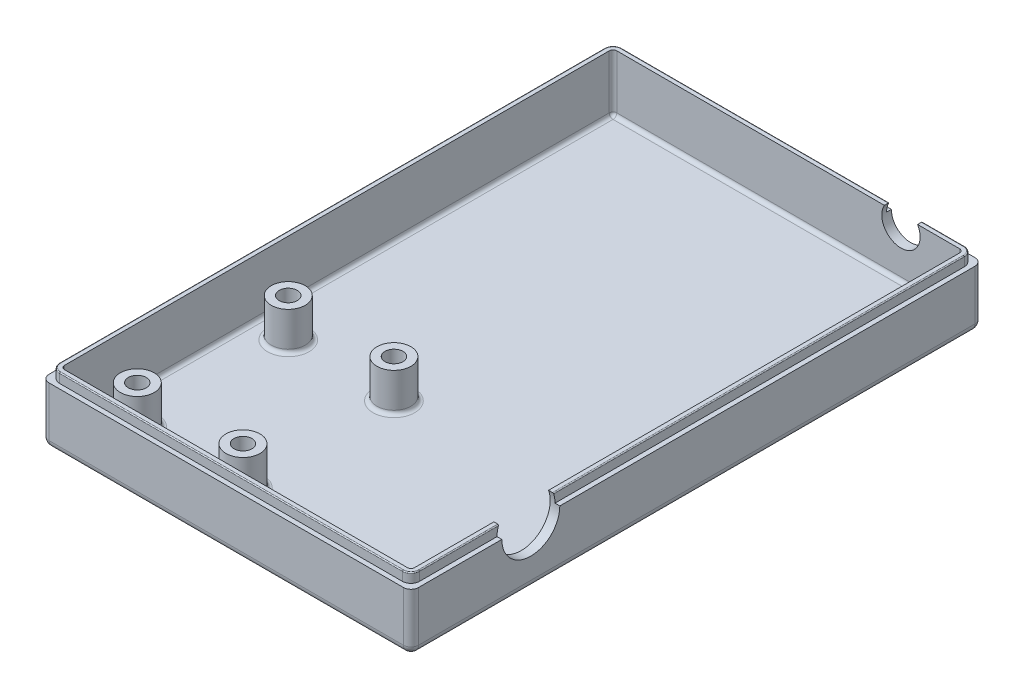
from build123d import *

# Parameters (mm, degrees)
SKETCH1_W                          = 97.882173792
SKETCH1_H                          = 151.414714432
BOSS_EXTRUDE1_DEPTH                = 1.27
SKETCH2_W                          = 97.882173792
SKETCH2_H                          = 151.414714432
SKETCH2_W_2                        = 92.802173792
SKETCH2_H_2                        = 146.334714432
BOSS_EXTRUDE2_DEPTH                = 12.7
SKETCH4_R                          = 4.500000017
SKETCH4_R_2                        = 4.5
BOSS_EXTRUDE3_DEPTH                = 10.16
FILLET1_R                          = 2
FILLET2_R                          = 1
FILLET3_R                          = 1
F_3_16_0_1875_DIAMETER_HOLE1_D     = 4.7625
F_3_16_0_1875_DIAMETER_HOLE1_DEPTH = 20.066
F_3_16_0_1875_DIAMETER_HOLE1_TIP   = 1.430799349
BOSS_EXTRUDE4_DEPTH                = 2.54
FILLET4_R                          = 0.254
SKETCH8_R                          = 7.6835
CUT_EXTRUDE1_DEPTH                 = 2.54
CUT_EXTRUDE2_REACH                 = 153.415
SKETCH10_R                         = 5.08


with BuildPart() as part:
    # Sketch1 → Boss-Extrude1 (new body, symmetric)
    with BuildSketch(Plane(origin=(0, 0, 0), x_dir=(1, 0, 0), z_dir=(0, 1, 0))):
        Rectangle(SKETCH1_W, SKETCH1_H)
    extrude(amount=BOSS_EXTRUDE1_DEPTH, both=True)

    # Sketch2 → Boss-Extrude2 (add)
    with BuildSketch(Plane(origin=(0, 1.27, 0), x_dir=(1, 0, 0), z_dir=(0, 1, 0))):
        Rectangle(SKETCH2_W, SKETCH2_H)
        Rectangle(SKETCH2_W_2, SKETCH2_H_2, mode=Mode.SUBTRACT)
    extrude(amount=BOSS_EXTRUDE2_DEPTH)

    # Sketch4 → Boss-Extrude3 (add)
    with BuildSketch(Plane(origin=(0, 1.27, 0), x_dir=(1, 0, 0), z_dir=(0, 1, 0))):
        with Locations((-9.861086891, -21.423024629)):
            Circle(SKETCH4_R)
        with Locations((-37.861086891, -61.423024629)):
            Circle(SKETCH4_R_2)
        with Locations((-9.861086891, -61.423024629)):
            Circle(SKETCH4_R)
        with Locations((-37.861086891, -21.423024629)):
            Circle(SKETCH4_R_2)
    extrude(amount=BOSS_EXTRUDE3_DEPTH)

    # Fillet1
    fillet1_edges = [part.edges().sort_by_distance(p)[0] for p in [
        (-48.941086896, -1.27, 0),
        (0, -1.27, -75.707357216),
        (48.941086896, -1.27, 0),
        (0, -1.27, 75.707357216),
        (-48.941086896, 6.35, 75.707357216),
        (-48.941086896, 6.35, -75.707357216),
        (48.941086896, 6.35, -75.707357216),
        (48.941086896, 6.35, 75.707357216),
    ]]
    fillet(fillet1_edges, radius=FILLET1_R)

    # Fillet2
    fillet2_edges = [part.edges().sort_by_distance(p)[0] for p in [
        (0, 1.27, -73.167357216),
        (-46.401086896, 1.27, 0),
        (0, 1.27, 73.167357216),
        (46.401086896, 1.27, 0),
        (-46.401086896, 7.62, -73.167357216),
        (-46.401086896, 7.62, 73.167357216),
        (46.401086896, 7.62, 73.167357216),
        (46.401086896, 7.62, -73.167357216),
    ]]
    fillet(fillet2_edges, radius=FILLET2_R)

    # Fillet3
    fillet3_edges = [part.edges().sort_by_distance(p)[0] for p in [
        (-14.361086908, 1.27, 21.423024629),
        (-42.361086891, 1.27, 61.423024629),
        (-14.361086908, 1.27, 61.423024629),
        (-42.361086891, 1.27, 21.423024629),
    ]]
    fillet(fillet3_edges, radius=FILLET3_R)

    # 3/16 (0.1875) Diameter Hole1
    with Locations(Plane(origin=(0, 11.43, 0), x_dir=(1, 0, 0), z_dir=(0, 1, 0))):
        with Locations((-37.861086891, -21.423024629), (-37.861086891, -61.423024629), (-9.861086891, -21.423024629), (-9.861086891, -61.423024629)):
            Hole(F_3_16_0_1875_DIAMETER_HOLE1_D / 2, depth=F_3_16_0_1875_DIAMETER_HOLE1_DEPTH)
            with Locations((0, 0, -(F_3_16_0_1875_DIAMETER_HOLE1_DEPTH + F_3_16_0_1875_DIAMETER_HOLE1_TIP / 2))):  # 118° drill point
                Cone(0, F_3_16_0_1875_DIAMETER_HOLE1_D / 2, F_3_16_0_1875_DIAMETER_HOLE1_TIP, mode=Mode.SUBTRACT)

    # Sketch7 → Boss-Extrude4 (add)
    with BuildSketch(Plane(origin=(0, 13.97, 0), x_dir=(1, 0, 0), z_dir=(0, 1, 0))):
        with BuildLine():
            Line((45.401086896, -74.437357216), (-45.401086896, -74.437357216))
            ThreePointArc((-45.401086896, -74.437357216), (-47.00621929, -73.772489609), (-47.671086896, -72.167357216))
            Line((-47.671086896, -72.167357216), (-47.671086896, 72.167357216))
            ThreePointArc((-47.671086896, 72.167357216), (-47.00621929, 73.772489609), (-45.401086896, 74.437357216))
            Line((-45.401086896, 74.437357216), (45.401086896, 74.437357216))
            ThreePointArc((45.401086896, 74.437357216), (47.00621929, 73.772489609), (47.671086896, 72.167357216))
            Line((47.671086896, 72.167357216), (47.671086896, -72.167357216))
            ThreePointArc((47.671086896, -72.167357216), (47.00621929, -73.772489609), (45.401086896, -74.437357216))
        make_face()
        with BuildLine():
            Line((46.401086896, 72.167357216), (46.401086896, -72.167357216))
            ThreePointArc((46.401086896, -72.167357216), (46.108193678, -72.874463997), (45.401086896, -73.167357216))
            Line((45.401086896, -73.167357216), (-45.401086896, -73.167357216))
            ThreePointArc((-45.401086896, -73.167357216), (-46.108193678, -72.874463997), (-46.401086896, -72.167357216))
            Line((-46.401086896, -72.167357216), (-46.401086896, 72.167357216))
            ThreePointArc((-46.401086896, 72.167357216), (-46.108193678, 72.874463997), (-45.401086896, 73.167357216))
            Line((-45.401086896, 73.167357216), (45.401086896, 73.167357216))
            ThreePointArc((45.401086896, 73.167357216), (46.108193678, 72.874463997), (46.401086896, 72.167357216))
        make_face(mode=Mode.SUBTRACT)
    extrude(amount=BOSS_EXTRUDE4_DEPTH)

    # Fillet4
    fillet4_edges = [part.edges().sort_by_distance(p)[0] for p in [
        (47.00621929, 16.51, 73.772489609),
        (47.671086896, 16.51, 0),
        (47.00621929, 16.51, -73.772489609),
        (0, 16.51, -74.437357216),
        (-47.00621929, 16.51, -73.772489609),
        (-47.671086896, 16.51, 0),
        (-47.00621929, 16.51, 73.772489609),
        (0, 16.51, 74.437357216),
    ]]
    fillet(fillet4_edges, radius=FILLET4_R)

    # Sketch8 → Cut-Extrude1 (cut)
    with BuildSketch(Plane(origin=(48.941086896, 0, 0), x_dir=(0, 0, -1), z_dir=(1, 0, 0))):
        with Locations((-43.957357216, 13.97)):
            Circle(SKETCH8_R)
    extrude(amount=-CUT_EXTRUDE1_DEPTH, mode=Mode.SUBTRACT)

    # Sketch10 → Cut-Extrude2 (cut, up to next)
    with BuildSketch(Plane(origin=(0, 0, -75.707357216), x_dir=(-1, 0, 0), z_dir=(0, 0, -1)), mode=Mode.PRIVATE) as cut_extrude2_sk1:
        with Locations((-29.891086896, 13.97)):
            Circle(SKETCH10_R)
    cut_extrude2_tool1 = extrude(cut_extrude2_sk1.sketch, amount=-CUT_EXTRUDE2_REACH, mode=Mode.PRIVATE) & part.part
    add(cut_extrude2_tool1.solids().sort_by_distance((29.891087, 13.97, -75.707357))[0], mode=Mode.SUBTRACT)


solid = part.part
